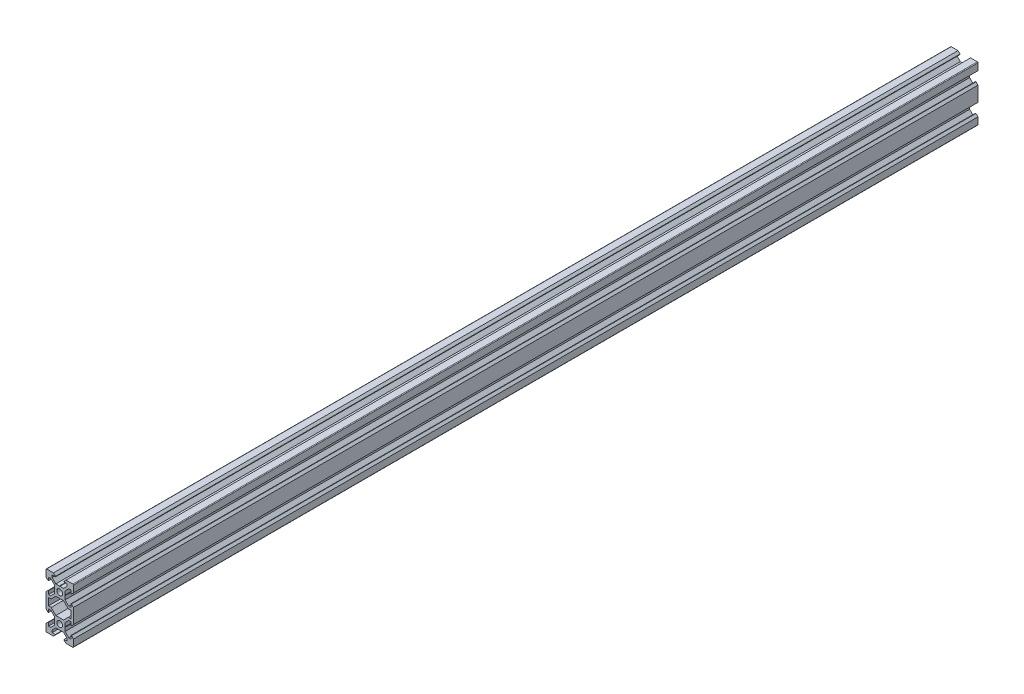
from build123d import *

# Parameters (mm, degrees)
SKETCH1_R           = 2.1
BOSS_EXTRUDE1_DEPTH = 660


with BuildPart() as part:
    # Sketch1 → Boss-Extrude1 (new body)
    with BuildSketch(Plane.XY):
        with BuildLine():
            Line((4.58, -20), (9.5, -20))
            ThreePointArc((9.5, -20), (9.853553391, -19.853553391), (10, -19.5))
            Line((10, -19.5), (10, -14.58))
            Line((10, -14.58), (8.545, -13.125))
            Line((8.545, -13.125), (8.2, -13.125))
            Line((8.2, -13.125), (8.2, -15.5))
            Line((8.2, -15.5), (6.560660172, -15.5))
            Line((6.560660172, -15.5), (3.9, -12.839339828))
            Line((3.9, -12.839339828), (3.9, -10.21))
            Line((3.9, -10.21), (3.69, -10))
            Line((3.69, -10), (3.9, -9.79))
            Line((3.9, -9.79), (3.9, -7.160660172))
            Line((3.9, -7.160660172), (6.560660172, -4.5))
            Line((6.560660172, -4.5), (8.2, -4.5))
            Line((8.2, -4.5), (8.2, -6.875))
            Line((8.2, -6.875), (8.545, -6.875))
            Line((8.545, -6.875), (10, -5.42))
            Line((10, -5.42), (10, 5.42))
            Line((10, 5.42), (8.545, 6.875))
            Line((8.545, 6.875), (8.2, 6.875))
            Line((8.2, 6.875), (8.2, 4.5))
            Line((8.2, 4.5), (6.560660172, 4.5))
            Line((6.560660172, 4.5), (3.9, 7.160660172))
            Line((3.9, 7.160660172), (3.9, 9.79))
            Line((3.9, 9.79), (3.69, 10))
            Line((3.69, 10), (3.9, 10.21))
            Line((3.9, 10.21), (3.9, 12.839339828))
            Line((3.9, 12.839339828), (6.560660172, 15.5))
            Line((6.560660172, 15.5), (8.2, 15.5))
            Line((8.2, 15.5), (8.2, 13.125))
            Line((8.2, 13.125), (8.545, 13.125))
            Line((8.545, 13.125), (10, 14.58))
            Line((10, 14.58), (10, 19.5))
            ThreePointArc((10, 19.5), (9.853553391, 19.853553391), (9.5, 20))
            Line((9.5, 20), (4.58, 20))
            Line((4.58, 20), (3.125, 18.545))
            Line((3.125, 18.545), (3.125, 18.2))
            Line((3.125, 18.2), (5.5, 18.2))
            Line((5.5, 18.2), (5.5, 16.560660172))
            Line((5.5, 16.560660172), (2.839339828, 13.9))
            Line((2.839339828, 13.9), (0.21, 13.9))
            Line((0.21, 13.9), (0, 13.69))
            Line((0, 13.69), (-0.21, 13.9))
            Line((-0.21, 13.9), (-2.839339828, 13.9))
            Line((-2.839339828, 13.9), (-5.5, 16.560660172))
            Line((-5.5, 16.560660172), (-5.5, 18.2))
            Line((-5.5, 18.2), (-3.125, 18.2))
            Line((-3.125, 18.2), (-3.125, 18.545))
            Line((-3.125, 18.545), (-4.58, 20))
            Line((-4.58, 20), (-9.5, 20))
            ThreePointArc((-9.5, 20), (-9.853553391, 19.853553391), (-10, 19.5))
            Line((-10, 19.5), (-10, 14.58))
            Line((-10, 14.58), (-8.545, 13.125))
            Line((-8.545, 13.125), (-8.2, 13.125))
            Line((-8.2, 13.125), (-8.2, 15.5))
            Line((-8.2, 15.5), (-6.560660172, 15.5))
            Line((-6.560660172, 15.5), (-3.9, 12.839339828))
            Line((-3.9, 12.839339828), (-3.9, 10.21))
            Line((-3.9, 10.21), (-3.69, 10))
            Line((-3.69, 10), (-3.9, 9.79))
            Line((-3.9, 9.79), (-3.9, 7.160660172))
            Line((-3.9, 7.160660172), (-6.560660172, 4.5))
            Line((-6.560660172, 4.5), (-8.2, 4.5))
            Line((-8.2, 4.5), (-8.2, 6.875))
            Line((-8.2, 6.875), (-8.545, 6.875))
            Line((-8.545, 6.875), (-10, 5.42))
            Line((-10, 5.42), (-10, -5.42))
            Line((-10, -5.42), (-8.545, -6.875))
            Line((-8.545, -6.875), (-8.2, -6.875))
            Line((-8.2, -6.875), (-8.2, -4.5))
            Line((-8.2, -4.5), (-6.560660172, -4.5))
            Line((-6.560660172, -4.5), (-3.9, -7.160660172))
            Line((-3.9, -7.160660172), (-3.9, -9.79))
            Line((-3.9, -9.79), (-3.69, -10))
            Line((-3.69, -10), (-3.9, -10.21))
            Line((-3.9, -10.21), (-3.9, -12.839339828))
            Line((-3.9, -12.839339828), (-6.560660172, -15.5))
            Line((-6.560660172, -15.5), (-8.2, -15.5))
            Line((-8.2, -15.5), (-8.2, -13.125))
            Line((-8.2, -13.125), (-8.545, -13.125))
            Line((-8.545, -13.125), (-10, -14.58))
            Line((-10, -14.58), (-10, -19.5))
            ThreePointArc((-10, -19.5), (-9.853553391, -19.853553391), (-9.5, -20))
            Line((-9.5, -20), (-4.58, -20))
            Line((-4.58, -20), (-3.125, -18.545))
            Line((-3.125, -18.545), (-3.125, -18.2))
            Line((-3.125, -18.2), (-5.5, -18.2))
            Line((-5.5, -18.2), (-5.5, -16.560660172))
            Line((-5.5, -16.560660172), (-2.839339828, -13.9))
            Line((-2.839339828, -13.9), (-0.21, -13.9))
            Line((-0.21, -13.9), (0, -13.69))
            Line((0, -13.69), (0.21, -13.9))
            Line((0.21, -13.9), (2.839339828, -13.9))
            Line((2.839339828, -13.9), (5.5, -16.560660172))
            Line((5.5, -16.560660172), (5.5, -18.2))
            Line((5.5, -18.2), (3.125, -18.2))
            Line((3.125, -18.2), (3.125, -18.545))
            Line((3.125, -18.545), (4.58, -20))
        make_face()
        with Locations((0, -10)):
            Circle(SKETCH1_R, mode=Mode.SUBTRACT)
        Polygon((-6.239339828, -2.7), (-8.2, -2.7), (-8.2, 2.7), (-6.239339828, 2.7), (-2.839339828, 6.1), (2.839339828, 6.1), (6.239339828, 2.7), (8.2, 2.7), (8.2, -2.7), (6.239339828, -2.7), (2.839339828, -6.1), (-2.839339828, -6.1), align=None, mode=Mode.SUBTRACT)
        with Locations((0, 10)):
            Circle(SKETCH1_R, mode=Mode.SUBTRACT)
    extrude(amount=BOSS_EXTRUDE1_DEPTH)


solid = part.part
